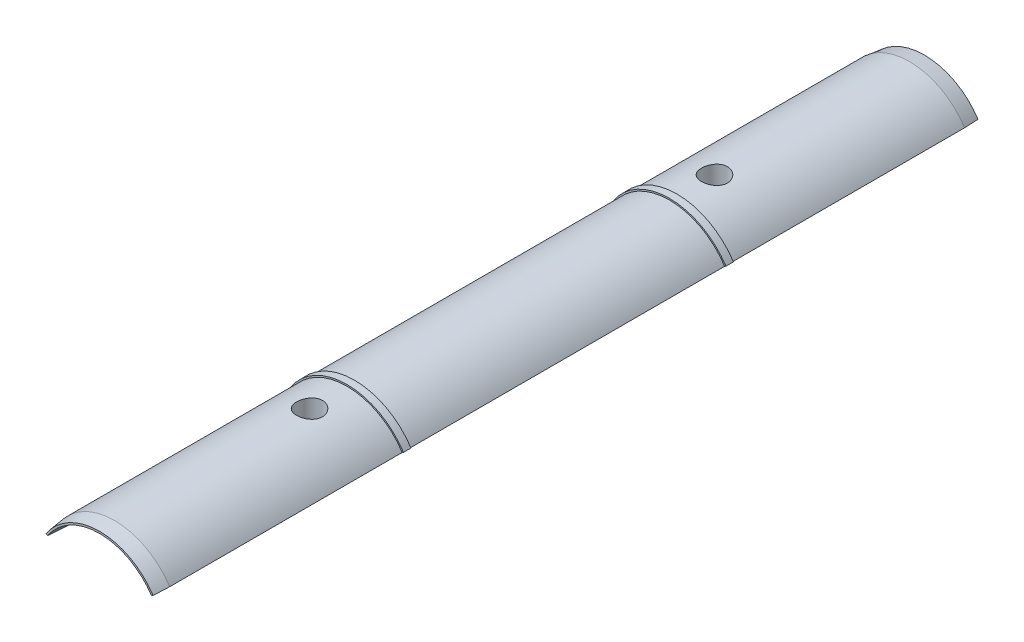
from build123d import *

# Parameters (mm, degrees)
F_8_32_TAPPED_HOLE1_D     = 3.4544
F_8_32_TAPPED_HOLE1_DEPTH = 10
F_8_32_TAPPED_HOLE1_TIP   = 1.037806461
CUT_EXTRUDE1_DEPTH        = 56


with BuildPart() as part:
    # Sketch1 → Revolve1 (revolve)
    with BuildSketch(Plane(origin=(0, 0, 0), x_dir=(1, 0, 0), z_dir=(0, 1, 0))):
        Polygon((4.6852, 0), (4.6852, 32), (7.227877139, 34.542677139), (8.3, 55), (8.55, 55), (8.8, 53), (8.8, 32), (8.8, 22), (9, 22), (9, 21), (8.8, 21), (8.8, 0), align=None)
    revolve(axis=Axis((0, 0, 0), (0, 0, -1)))

    # 8-32 Tapped Hole1
    with Locations(Plane(origin=(0, 8.8, -27), x_dir=(1, 0, 0), z_dir=(0, 1, 0))):
        with Locations((0, 0)):
            Hole(F_8_32_TAPPED_HOLE1_D / 2, depth=F_8_32_TAPPED_HOLE1_DEPTH)
            with Locations((0, 0, -(F_8_32_TAPPED_HOLE1_DEPTH + F_8_32_TAPPED_HOLE1_TIP / 2))):  # 118° drill point
                Cone(0, F_8_32_TAPPED_HOLE1_D / 2, F_8_32_TAPPED_HOLE1_TIP, mode=Mode.SUBTRACT)

    # Sketch3 → Cut-Extrude1 (cut, through all)
    with BuildSketch(Plane.XY):
        with BuildLine():
            Line((7.532191208, 4.926062891), (0, 0.577350269))
            Line((0, 0.577350269), (-7.532191208, 4.926062891))
            ThreePointArc((-7.532191208, 4.926062891), (0, -9), (7.532191208, 4.926062891))
        make_face()
    extrude(amount=-CUT_EXTRUDE1_DEPTH, mode=Mode.SUBTRACT)

    # Mirror1: part across plane


with BuildPart() as part_1:
    add(part.part)
    add(part.part.mirror(Plane(origin=(8.8, 0, 0), x_dir=(1, 0, 0), z_dir=(0, 0, 1))))


solid = part_1.part
